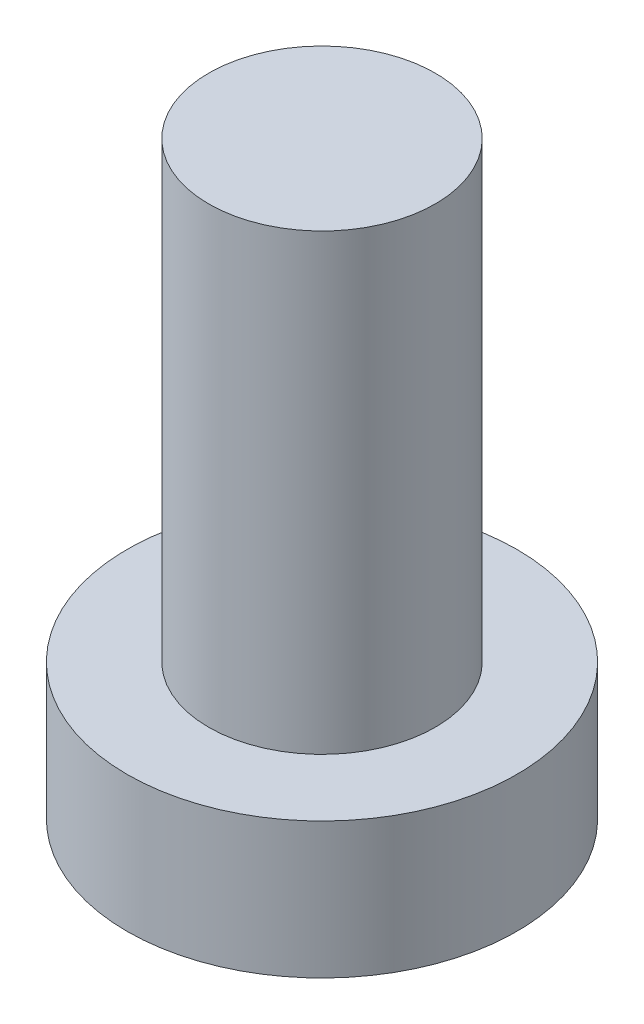
from build123d import *

# Parameters (mm, degrees)
SKETCH_1_R          = 4.3
EXTRUDE_1_DEPTH     = 3
SKETCH_2_R          = 2.5
EXTRUDE_2_DEPTH     = 10
CUT_EXTRUDE_1_DEPTH = 1.5


with BuildPart() as part:
    # 草图1 → 凸台-拉伸1 (new body)
    with BuildSketch(Plane(origin=(0, 0, 0), x_dir=(1, 0, 0), z_dir=(0, 1, 0))):
        Circle(SKETCH_1_R)
    extrude(amount=EXTRUDE_1_DEPTH)

    # 草图2 → 凸台-拉伸2 (add)
    with BuildSketch(Plane(origin=(0, 3, 0), x_dir=(1, 0, 0), z_dir=(0, 1, 0))):
        Circle(SKETCH_2_R)
    extrude(amount=EXTRUDE_2_DEPTH)

    # 草图3 → 切除-拉伸1 (cut)
    with BuildSketch(Plane.XZ):
        with BuildLine():
            Line((-0.6, 1.1), (-0.6, 2.4))
            Line((-0.6, 2.4), (0.6, 2.4))
            Line((0.6, 2.4), (0.6, 1.1))
            ThreePointArc((0.6, 1.1), (0.746446609, 0.746446609), (1.1, 0.6))
            Line((1.1, 0.6), (2.4, 0.6))
            Line((2.4, 0.6), (2.4, -0.6))
            Line((2.4, -0.6), (1.1, -0.6))
            ThreePointArc((1.1, -0.6), (0.746446609, -0.746446609), (0.6, -1.1))
            Line((0.6, -1.1), (0.6, -2.4))
            Line((0.6, -2.4), (-0.6, -2.4))
            Line((-0.6, -2.4), (-0.6, -1.1))
            ThreePointArc((-0.6, -1.1), (-0.746446609, -0.746446609), (-1.1, -0.6))
            Line((-1.1, -0.6), (-2.4, -0.6))
            Line((-2.4, -0.6), (-2.4, 0.6))
            Line((-2.4, 0.6), (-1.1, 0.6))
            ThreePointArc((-1.1, 0.6), (-0.746446609, 0.746446609), (-0.6, 1.1))
        make_face()
    extrude(amount=-CUT_EXTRUDE_1_DEPTH, mode=Mode.SUBTRACT)


solid = part.part
